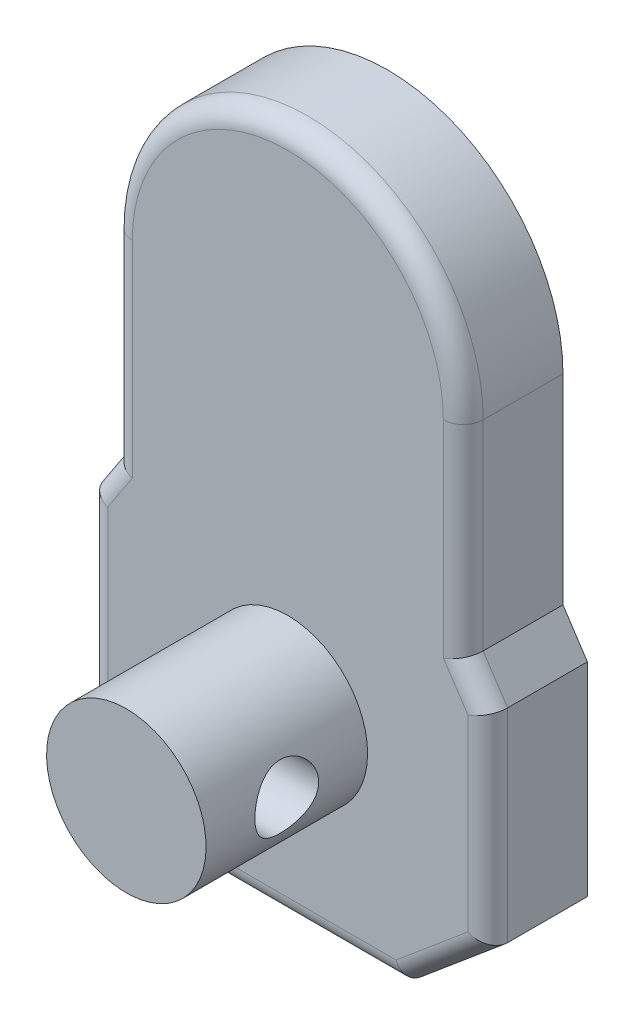
from build123d import *

# Parameters (mm, degrees)
BODY_DEPTH               = 10
SKETCH3_W                = 16.2
SKETCH3_H                = 8
SKETCH7_R                = 3.2
REAR_MOUNTING_DEPTH      = 21.05
REAR_MOUNTING_DEPTH_BACK = 21.05
SKETCH8_R                = 2.4
HOLE_DEPTH               = 8.5
FILLET4_R                = 2


with BuildPart() as part:
    # Sketch1 → Body (new body)
    with BuildSketch(Plane.XY.offset(130.3)):
        with BuildLine():
            Line((20.05, 9), (17.6, 12.720551034))
            Line((17.6, 12.720551034), (17.6, 32.8))
            ThreePointArc((17.6, 32.8), (12.445079349, 45.245079349), (0, 50.4))
            ThreePointArc((0, 50.4), (-12.445079349, 45.245079349), (-17.6, 32.8))
            Line((-17.6, 32.8), (-17.6, 12.720551034))
            Line((-17.6, 12.720551034), (-20.05, 9))
            Line((-20.05, 9), (-20.05, 0))
            Line((-20.05, 0), (-20.05, -11.4))
            Line((-20.05, -11.4), (-11.588549493, -18.5))
            Line((-11.588549493, -18.5), (-7.016550666, -18.5))
            Line((-7.016550666, -18.5), (7.016550666, -18.5))
            Line((7.016550666, -18.5), (11.588549493, -18.5))
            Line((11.588549493, -18.5), (20.05, -11.4))
            Line((20.05, -11.4), (20.05, 0))
            Line((20.05, 0), (20.05, 9))
        make_face()
    extrude(amount=BODY_DEPTH)

    # Sketch3 → Motor-Body (revolve)
    with BuildSketch(Plane(origin=(0, 0, 0), x_dir=(0, 0, -1), z_dir=(1, 0, 0))):
        with Locations((-148.4, 4)):
            Rectangle(SKETCH3_W, SKETCH3_H)
    revolve(axis=Axis((0, 0, -96.607444662), (0, 0, 1)))

    # Sketch7 → Rear-Mounting (cut, two sides)
    with BuildSketch(Plane(origin=(0, 0, 0), x_dir=(0, 0, -1), z_dir=(1, 0, 0))) as rear_mounting_sk:
        with Locations((-148.4, 0)):
            Circle(SKETCH7_R)
    extrude(amount=REAR_MOUNTING_DEPTH, mode=Mode.SUBTRACT)
    extrude(rear_mounting_sk.sketch, amount=-REAR_MOUNTING_DEPTH_BACK, mode=Mode.SUBTRACT)

    # Sketch8 → Hole (cut)
    with BuildSketch(Plane.XY.offset(130.3)):
        with Locations((16, -9)):
            Circle(SKETCH8_R)
        with Locations((-16, -9)):
            Circle(SKETCH8_R)
        with Locations((-16, 9)):
            Circle(SKETCH8_R)
        with Locations((16, 9)):
            Circle(SKETCH8_R)
    extrude(amount=HOLE_DEPTH, mode=Mode.SUBTRACT)

    # Fillet4
    fillet4_edges = [part.edges().sort_by_distance(p)[0] for p in [
        (-17.6, 22.760275517, 140.3),
        (-18.825, 10.860275517, 140.3),
        (-20.05, -1.2, 140.3),
        (-15.819274746, -14.95, 140.3),
        (0, -18.5, 140.3),
        (15.819274746, -14.95, 140.3),
        (20.05, -1.2, 140.3),
        (0, 50.4, 140.3),
        (18.825, 10.860275517, 140.3),
        (17.6, 22.760275517, 140.3),
    ]]
    fillet(fillet4_edges, radius=FILLET4_R)


solid = part.part
